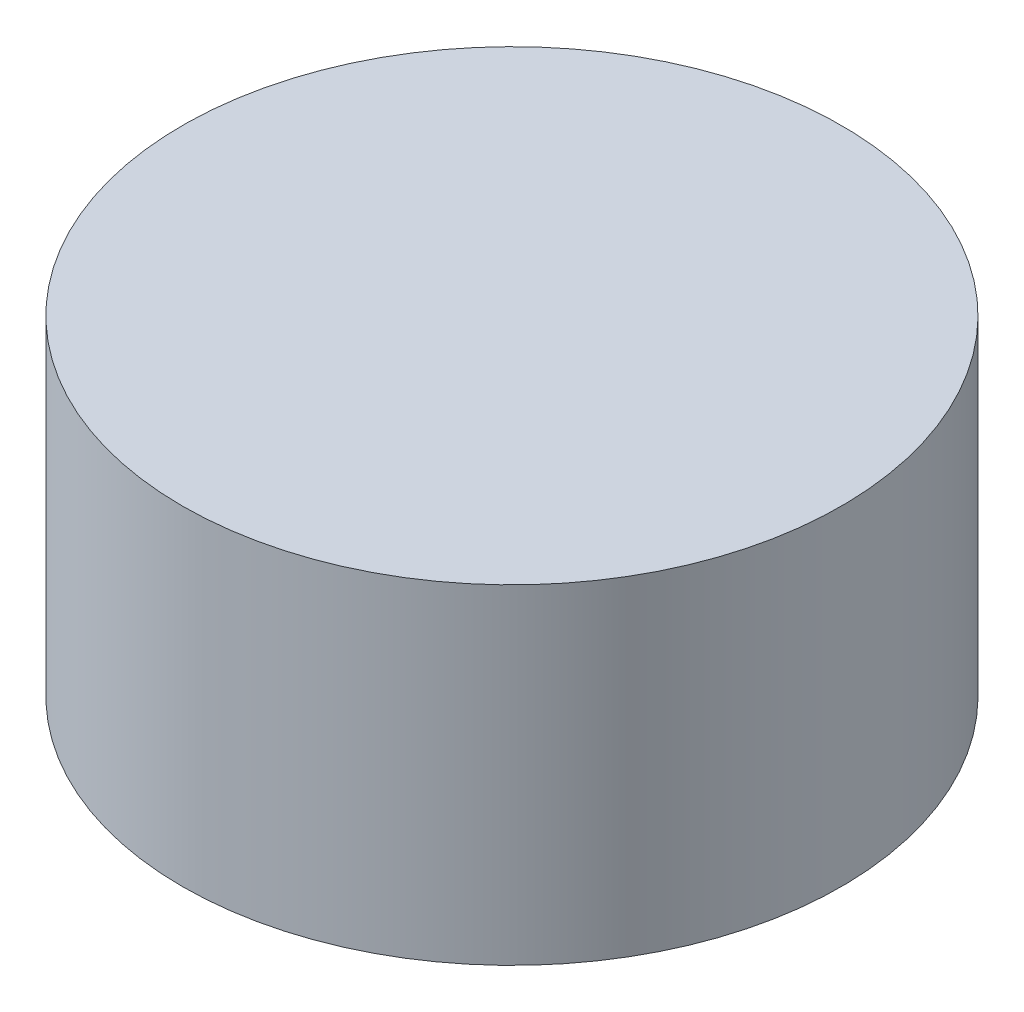
from build123d import *

# Parameters (mm, degrees)
SKETCH1_R  = 2
BASE_DEPTH = 2


with BuildPart() as part:
    # Sketch1 → Base (new body)
    with BuildSketch(Plane(origin=(0, 0, 0), x_dir=(1, 0, 0), z_dir=(0, 1, 0))):
        Circle(SKETCH1_R)
    extrude(amount=BASE_DEPTH)


solid = part.part
